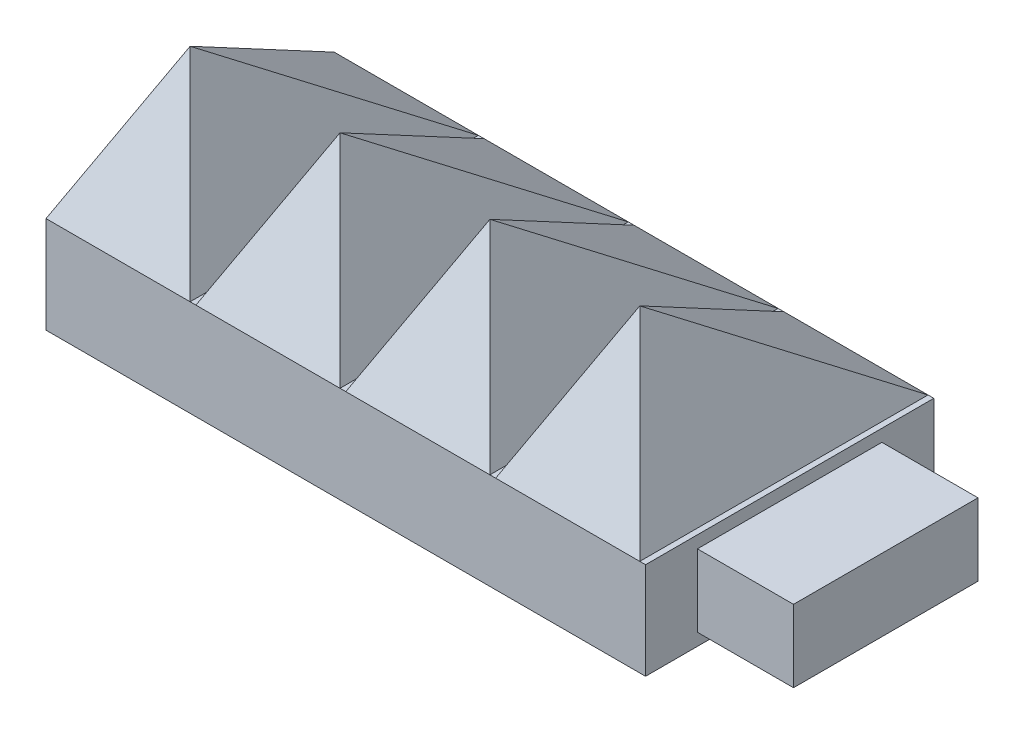
from build123d import *

# Parameters (mm, degrees)
SKETCH1_W           = 19.05
SKETCH1_H           = 19.05
BOSS_EXTRUDE2_DEPTH = 6.35
SKETCH8_W           = 217.17
SKETCH8_H           = 38.1
BOSS_EXTRUDE4_DEPTH = 6.35
SKETCH8_5_W         = 217.17
SKETCH8_5_H         = 38.1
BOSS_EXTRUDE5_DEPTH = 6.4262
SKETCH9_W           = 19.05
SKETCH9_H           = 38.1
LPATTERN3_COUNT     = 11
LPATTERN3_PITCH     = 19.812
SKETCH15_R          = 12.192
BOSS_EXTRUDE6_DEPTH = 6.35
SKETCH16_W          = 57.265249545
SKETCH16_H          = 42.292481859
CUT_EXTRUDE1_DEPTH  = 137.922
SKETCH17_W          = 24.384
SKETCH17_H          = 9.5504
BOSS_EXTRUDE7_DEPTH = 12.7


with BuildPart() as part:
    # Sketch1 → Boss-Extrude2 (new body)
    with BuildSketch(Plane(origin=(0, 0, 0), x_dir=(1, 0, 0), z_dir=(0, 1, 0))):
        with Locations((9.525, -9.525)):
            Rectangle(SKETCH1_W, SKETCH1_H)
    extrude(amount=BOSS_EXTRUDE2_DEPTH)

    # Sketch8 → Boss-Extrude4 (add)
    with BuildSketch(Plane(origin=(0, 0, 0), x_dir=(1, 0, 0), z_dir=(0, 1, 0))):
        with Locations((108.585, -9.525)):
            Rectangle(SKETCH8_W, SKETCH8_H)
    extrude(amount=BOSS_EXTRUDE4_DEPTH)

    # Sketch8_5 → Boss-Extrude5 (add)
    with BuildSketch(Plane(origin=(0, 0, 0), x_dir=(1, 0, 0), z_dir=(0, 1, 0))):
        with Locations((108.585, -9.525)):
            Rectangle(SKETCH8_5_W, SKETCH8_5_H)
    extrude(amount=-BOSS_EXTRUDE5_DEPTH)

    # Sketch9 → Loft3 section 0
    with BuildSketch(Plane(origin=(0, 6.35, 0), x_dir=(1, 0, 0), z_dir=(0, 1, 0)), mode=Mode.PRIVATE) as loft3_s0:
        with Locations((9.525, -9.525)):
            Rectangle(SKETCH9_W, SKETCH9_H)
    loft3 = loft([loft3_s0.sketch, Vertex(9.525, 26.0731, 19.05)])

    # LPattern3: Loft3 ×11
    with Locations(*[(i * LPATTERN3_PITCH, 0, 0) for i in range(1, LPATTERN3_COUNT)]):
        add(loft3)

    # Sketch15 → Boss-Extrude6 (add)
    with BuildSketch(Plane.XZ.offset(6.4262)):
        with Locations((179.07, 9.525)):
            Circle(SKETCH15_R)
        with Locations((38.1, 9.525)):
            Circle(SKETCH15_R)
        with Locations((108.585, 9.525)):
            Circle(SKETCH15_R)
    extrude(amount=BOSS_EXTRUDE6_DEPTH)

    # Sketch16 → Cut-Extrude1 (cut)
    with BuildSketch(Plane(origin=(217.17, 0, 0), x_dir=(0, 0, -1), z_dir=(1, 0, 0))):
        with Locations((-10.111619629, 6.16028271)):
            Rectangle(SKETCH16_W, SKETCH16_H)
    extrude(amount=-CUT_EXTRUDE1_DEPTH, mode=Mode.SUBTRACT)

    # Sketch17 → Boss-Extrude7 (add)
    with BuildSketch(Plane(origin=(79.248, 0, 0), x_dir=(0, 0, -1), z_dir=(1, 0, 0))):
        with Locations((-9.525, -0.0381)):
            Rectangle(SKETCH17_W, SKETCH17_H)
    extrude(amount=BOSS_EXTRUDE7_DEPTH)


solid = part.part
